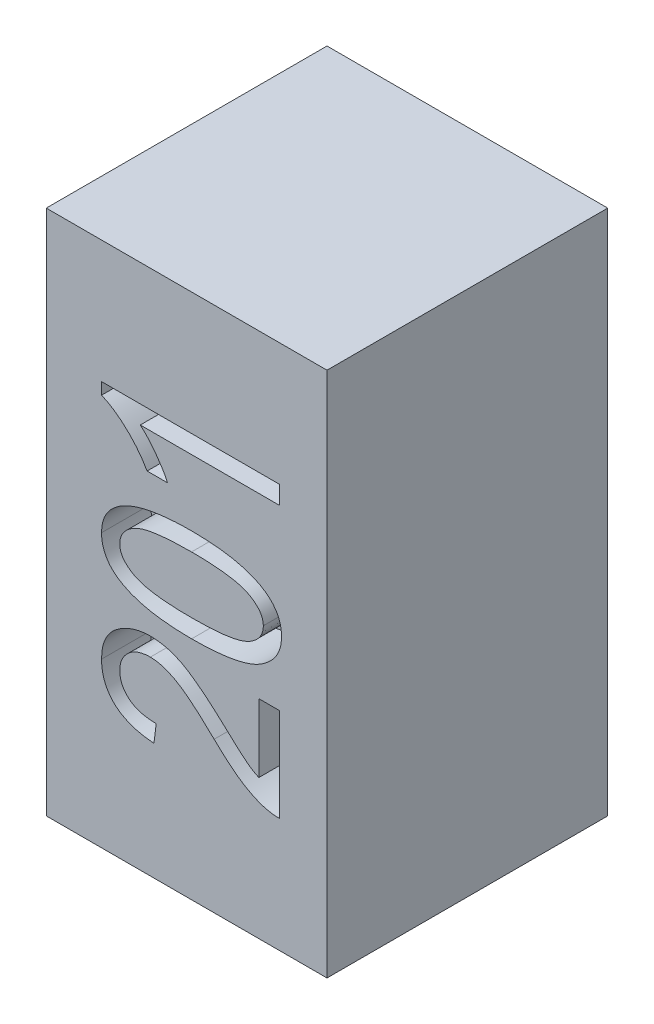
from build123d import *

# Parameters (mm, degrees)
ESQUISSE1_W             = 0.8
ESQUISSE1_H             = 1.5
BOSS_EXTRU_1_DEPTH      = 0.8
ENL_V_MAT_EXTRU_1_DEPTH = 0.14


with BuildPart() as part:
    # Esquisse1 → Boss.-Extru.1 (new body)
    with BuildSketch(Plane.XY):
        Rectangle(ESQUISSE1_W, ESQUISSE1_H)
    extrude(amount=BOSS_EXTRU_1_DEPTH)

    # Esquisse2 → Enlèv. mat.-Extru.1 (cut)
    with BuildSketch(Plane.XY.offset(0.8)):
        with BuildLine():
            Line((0.205570813, -0.157792208), (0.264012371, -0.157792208))
            Line((0.264012371, -0.157792208), (0.264012371, -0.424025974))
            add(Edge.make_bspline(
                [(0.264012371, -0.424025974), (0.260967321, -0.424038301), (0.254798001, -0.424063275), (0.245392327, -0.423232959), (0.235758937, -0.421527003), (0.22576932, -0.41934867), (0.215554854, -0.416260038), (0.205065936, -0.412478951), (0.194328572, -0.408017717), (0.183279597, -0.402793554), (0.171811295, -0.396690753), (0.159978819, -0.389318491), (0.147562351, -0.38089399), (0.134716726, -0.371213142), (0.12131985, -0.360450116), (0.10743377, -0.348551795), (0.092982188, -0.33556787), (0.083383466, -0.326315361), (0.078440131, -0.321550325)],
                knots=[0, 0, 0, 0, 0.672196011, 1.361880106, 2.081368845, 2.831486093, 3.618364569, 4.435734711, 5.292876118, 6.184871288, 7.133796945, 8.159796293, 9.26180684, 10.446293416, 11.710635831, 13.056147575, 14.483918136, 16, 16, 16, 16], degree=3))
            add(Edge.make_bspline(
                [(0.078440131, -0.321550325), (0.072713346, -0.316013609), (0.061686867, -0.305353093), (0.045405594, -0.290349435), (0.030272354, -0.276717105), (0.016013492, -0.264728468), (0.002823211, -0.254170682), (-0.009279632, -0.244937524), (-0.020569702, -0.237470246), (-0.033854091, -0.229407709), (-0.049668946, -0.221721226), (-0.068103661, -0.214925939), (-0.085924545, -0.210535314), (-0.097673474, -0.210000119), (-0.103378051, -0.20974026)],
                knots=[0, 0, 0, 0, 1.312560889, 2.527233899, 3.64818266, 4.668586789, 5.596397896, 6.432357998, 7.175835261, 7.825761013, 8.992224112, 10.065918602, 11.060925749, 12, 12, 12, 12], degree=3))
            add(Edge.make_bspline(
                [(-0.103378051, -0.20974026), (-0.106527438, -0.209776484), (-0.112678521, -0.209847234), (-0.121661412, -0.211049977), (-0.130205936, -0.212764574), (-0.138371976, -0.215030711), (-0.146032105, -0.218235162), (-0.153239808, -0.222118312), (-0.160090015, -0.226558591), (-0.16634486, -0.231739982), (-0.171987603, -0.237403608), (-0.177039168, -0.243386687), (-0.181168118, -0.24979007), (-0.184588242, -0.256481802), (-0.187205121, -0.26350197), (-0.18916589, -0.27083284), (-0.19027981, -0.278496857), (-0.190447822, -0.283701918), (-0.190533084, -0.286343344)],
                knots=[0, 0, 0, 0, 1.164144409, 2.273695819, 3.345940663, 4.387378487, 5.402712487, 6.410231049, 7.41307794, 8.417484468, 9.408318902, 10.367853362, 11.308274301, 12.220303706, 13.142827832, 14.074469365, 15.022846069, 16, 16, 16, 16], degree=3))
            add(Edge.make_bspline(
                [(-0.190533084, -0.286343344), (-0.190473575, -0.289191353), (-0.190357413, -0.294750798), (-0.188904765, -0.302851707), (-0.186978054, -0.3106229), (-0.183932032, -0.317967239), (-0.180250547, -0.325024618), (-0.175445024, -0.331504716), (-0.170081997, -0.337780215), (-0.163790342, -0.343548772), (-0.156646186, -0.34869795), (-0.148843257, -0.35331999), (-0.140187308, -0.357045393), (-0.130892263, -0.360176192), (-0.120846841, -0.362635434), (-0.110082061, -0.364277355), (-0.098602527, -0.36548204), (-0.09069885, -0.365549663), (-0.08663698, -0.365584416)],
                knots=[0, 0, 0, 0, 0.928593091, 1.812656339, 2.680433, 3.537535669, 4.402074609, 5.272376737, 6.164676777, 7.094647554, 8.050991042, 9.035788945, 10.049325173, 11.121325706, 12.235436061, 13.420862991, 14.67452591, 16, 16, 16, 16], degree=3))
            Line((-0.08663698, -0.365584416), (-0.093130486, -0.417532468))
            add(Edge.make_bspline(
                [(-0.093130486, -0.417532468), (-0.099158652, -0.416997129), (-0.110853567, -0.415958547), (-0.127783653, -0.413233388), (-0.143492174, -0.409452488), (-0.158133879, -0.404961846), (-0.171533811, -0.399320802), (-0.183937305, -0.39297169), (-0.195128619, -0.385547018), (-0.205126511, -0.377201807), (-0.213893319, -0.368005987), (-0.221512807, -0.358126763), (-0.228121098, -0.347610622), (-0.233366685, -0.336309555), (-0.237456792, -0.324298316), (-0.240381042, -0.311621674), (-0.242125018, -0.298228873), (-0.242360676, -0.289088026), (-0.242481136, -0.284415584)],
                knots=[0, 0, 0, 0, 1.296016433, 2.514330702, 3.668705393, 4.754684394, 5.790583066, 6.778804856, 7.735156204, 8.660808185, 9.562568342, 10.450784178, 11.329227516, 12.217177451, 13.112894374, 14.042449809, 14.999377131, 16, 16, 16, 16], degree=3))
            add(Edge.make_bspline(
                [(-0.242481136, -0.284415584), (-0.242334143, -0.279370388), (-0.242047925, -0.269546551), (-0.240132911, -0.255252879), (-0.236832082, -0.241881659), (-0.231978869, -0.22952981), (-0.226018589, -0.218063044), (-0.218616149, -0.207585073), (-0.209815824, -0.198106808), (-0.19978414, -0.189679492), (-0.188958514, -0.182229823), (-0.177637379, -0.175730042), (-0.16600985, -0.170091862), (-0.153946139, -0.165685499), (-0.141608258, -0.162005708), (-0.128809151, -0.159693985), (-0.115696505, -0.158066548), (-0.106832896, -0.157884171), (-0.102363441, -0.157792208)],
                knots=[0, 0, 0, 0, 1.141316638, 2.222333051, 3.255980828, 4.24919085, 5.217781249, 6.173073686, 7.14226832, 8.135684626, 9.131102602, 10.111468148, 11.086834621, 12.050425614, 13.014198859, 13.995608887, 14.989290351, 16, 16, 16, 16], degree=3))
            add(Edge.make_bspline(
                [(-0.102363441, -0.157792208), (-0.098336657, -0.157878854), (-0.090335553, -0.158051019), (-0.078397452, -0.159170963), (-0.06661985, -0.161147874), (-0.0548895, -0.163714802), (-0.043388036, -0.167357299), (-0.03193276, -0.171480772), (-0.020653006, -0.176482333), (-0.009328199, -0.182386382), (0.002440813, -0.189300966), (0.014875652, -0.197579536), (0.028301082, -0.207121874), (0.042559397, -0.218122177), (0.057808298, -0.230404693), (0.073926762, -0.244127866), (0.090947705, -0.25924549), (0.102503356, -0.269888004), (0.108472598, -0.275385552)],
                knots=[0, 0, 0, 0, 0.780531358, 1.550893666, 2.321451189, 3.094347453, 3.876089108, 4.657940698, 5.453333384, 6.265487087, 7.132311241, 8.097757185, 9.160053187, 10.324349312, 11.587703087, 12.955031265, 14.427076445, 16, 16, 16, 16], degree=3))
            add(Edge.make_bspline(
                [(0.108472598, -0.275385552), (0.112183556, -0.278879066), (0.119275494, -0.285555453), (0.129562543, -0.294945868), (0.138788252, -0.303550685), (0.147186165, -0.311077417), (0.154576407, -0.317770468), (0.161200839, -0.323272064), (0.166736734, -0.328002498), (0.17560759, -0.334903517), (0.18812033, -0.343612846), (0.199888131, -0.349671617), (0.205570813, -0.352597403)],
                knots=[0, 0, 0, 0, 1.227426371, 2.345710398, 3.354421158, 4.265580894, 5.061720194, 5.755250507, 6.339260457, 6.815034732, 8.461977265, 10, 10, 10, 10], degree=3))
            Line((0.205570813, -0.352597403), (0.205570813, -0.157792208))
        make_face()
        with BuildLine():
            add(Edge.make_bspline(
                [(0.014215293, -0.105844156), (0.00399922, -0.105761675), (-0.015837938, -0.105601516), (-0.044609423, -0.103945955), (-0.071488621, -0.101335365), (-0.096438423, -0.097782979), (-0.119466175, -0.092983086), (-0.140627467, -0.087297112), (-0.15986302, -0.080395334), (-0.177188392, -0.07253586), (-0.192536194, -0.063617321), (-0.205858138, -0.053609545), (-0.217263689, -0.042656053), (-0.22651725, -0.030532414), (-0.233692827, -0.01742418), (-0.238823201, -0.003303949), (-0.241927102, 0.011816903), (-0.242293956, 0.022252539), (-0.242481136, 0.02757711)],
                knots=[0, 0, 0, 0, 1.522177082, 2.955701814, 4.292601031, 5.54555501, 6.7088804, 7.795771162, 8.808034672, 9.750647735, 10.627079958, 11.44753433, 12.228026558, 12.97593222, 13.711165822, 14.446140298, 15.20717461, 16, 16, 16, 16], degree=3))
            add(Edge.make_bspline(
                [(-0.242481136, 0.02757711), (-0.242343665, 0.032325199), (-0.242073528, 0.041655493), (-0.23939859, 0.055203234), (-0.235410952, 0.068049624), (-0.229526205, 0.080007828), (-0.222033299, 0.09121315), (-0.212815704, 0.101532444), (-0.202069659, 0.111232722), (-0.193920757, 0.11675598), (-0.189721395, 0.119602273)],
                knots=[0, 0, 0, 0, 1.02455918, 2.013323352, 2.972239719, 3.92313388, 4.881632631, 5.875512573, 6.905191138, 8, 8, 8, 8], degree=3))
            add(Edge.make_bspline(
                [(-0.189721395, 0.119602273), (-0.184070449, 0.122906761), (-0.172318711, 0.129778793), (-0.15262831, 0.137981703), (-0.130607181, 0.144917692), (-0.106233242, 0.150703779), (-0.079455153, 0.154904795), (-0.050381541, 0.158180211), (-0.0188866, 0.160089392), (0.002916698, 0.160287137), (0.014215293, 0.16038961)],
                knots=[0, 0, 0, 0, 0.745752227, 1.550870435, 2.425309485, 3.376577511, 4.404263406, 5.514061028, 6.71177208, 8, 8, 8, 8], degree=3))
            add(Edge.make_bspline(
                [(0.014215293, 0.16038961), (0.024363793, 0.160307563), (0.044065899, 0.160148278), (0.072667599, 0.158485819), (0.099413205, 0.155885317), (0.124290401, 0.152311336), (0.147263096, 0.147557921), (0.168352217, 0.141789847), (0.187606852, 0.135073629), (0.204927074, 0.127150941), (0.220349309, 0.118262073), (0.233741727, 0.108322617), (0.245102485, 0.097331108), (0.254458804, 0.085318363), (0.261608729, 0.072121412), (0.266860059, 0.058002038), (0.269953242, 0.042794494), (0.270318788, 0.032326147), (0.270505877, 0.026968344)],
                knots=[0, 0, 0, 0, 1.514074965, 2.939396442, 4.273020662, 5.522618968, 6.687464393, 7.770909357, 8.782798299, 9.726643008, 10.608576586, 11.434138097, 12.208514389, 12.960468265, 13.696662544, 14.439073904, 15.201102606, 16, 16, 16, 16], degree=3))
            add(Edge.make_bspline(
                [(0.270505877, 0.026968344), (0.270326276, 0.022188285), (0.269973161, 0.012790151), (0.267293702, -0.001001731), (0.26265949, -0.014045815), (0.256334466, -0.026472562), (0.248066952, -0.038089397), (0.23813936, -0.049170611), (0.226282607, -0.05945192), (0.212666308, -0.069245108), (0.196783903, -0.07804048), (0.178321409, -0.085463968), (0.157341767, -0.09184165), (0.133695973, -0.09686382), (0.107531891, -0.101073339), (0.078722599, -0.103760103), (0.047347402, -0.105514272), (0.025547799, -0.105731322), (0.014215293, -0.105844156)],
                knots=[0, 0, 0, 0, 0.713852874, 1.403515076, 2.08903769, 2.775973907, 3.479633763, 4.213082677, 4.993526966, 5.819329379, 6.714934747, 7.698240864, 8.786642223, 9.986811405, 11.306714678, 12.743554856, 14.307139623, 16, 16, 16, 16], degree=3))
        make_face()
        with BuildLine():
            add(Edge.make_bspline(
                [(0.014012371, -0.053896104), (0.023753266, -0.053804511), (0.042395063, -0.053629225), (0.069098829, -0.052690151), (0.093263495, -0.050876509), (0.114937612, -0.048393253), (0.134119793, -0.045201835), (0.150848178, -0.041355587), (0.165024026, -0.036635794), (0.176895048, -0.031195896), (0.186756649, -0.025071177), (0.19525943, -0.018696281), (0.202450292, -0.01187819), (0.208299131, -0.004596883), (0.212954854, 0.003051859), (0.216227769, 0.011169445), (0.218243365, 0.019699782), (0.218452174, 0.025536849), (0.218557826, 0.02849026)],
                knots=[0, 0, 0, 0, 1.930680258, 3.694870612, 5.294765573, 6.732327541, 8.017244644, 9.14720992, 10.130763445, 10.973463911, 11.728776188, 12.427251247, 13.076760965, 13.687074849, 14.273357039, 14.844695938, 15.415444712, 16, 16, 16, 16], degree=3))
            add(Edge.make_bspline(
                [(0.218557826, 0.02849026), (0.218461448, 0.031277718), (0.218269544, 0.036827992), (0.216075404, 0.044920163), (0.21284843, 0.052714824), (0.208199172, 0.060132169), (0.202087522, 0.067007063), (0.194822671, 0.073654637), (0.186244352, 0.079928672), (0.176250494, 0.085919665), (0.164334792, 0.09141462), (0.150040274, 0.095948655), (0.133344716, 0.09984666), (0.114234082, 0.103069369), (0.092646706, 0.105382264), (0.068626681, 0.107245064), (0.04212419, 0.108170612), (0.023651686, 0.108348653), (0.014012371, 0.108441558)],
                knots=[0, 0, 0, 0, 0.556166894, 1.107416796, 1.665226727, 2.239567038, 2.848554421, 3.499699756, 4.205927923, 4.970429246, 5.826979258, 6.823810641, 7.964115301, 9.254120602, 10.697341843, 12.305131035, 14.071945012, 16, 16, 16, 16], degree=3))
            add(Edge.make_bspline(
                [(0.014012371, 0.108441558), (0.004271518, 0.108349194), (-0.014403992, 0.10817211), (-0.041142077, 0.10724067), (-0.065373037, 0.105413835), (-0.087083205, 0.102947816), (-0.106297316, 0.099745703), (-0.123028138, 0.095903811), (-0.137196882, 0.091173336), (-0.149063029, 0.085777102), (-0.158835349, 0.079572528), (-0.167378709, 0.073287332), (-0.174387666, 0.066283507), (-0.180314862, 0.059035496), (-0.184924591, 0.051282265), (-0.188223602, 0.043041159), (-0.190207639, 0.034367945), (-0.190424146, 0.028432757), (-0.190533084, 0.025446429)],
                knots=[0, 0, 0, 0, 1.925955125, 3.692509702, 5.288489091, 6.729174103, 8.01094651, 9.138146317, 10.1192927, 10.959930748, 11.707705856, 12.404471472, 13.052253553, 13.661073759, 14.251664904, 14.827808546, 15.410204315, 16, 16, 16, 16], degree=3))
            add(Edge.make_bspline(
                [(-0.190533084, 0.025446429), (-0.190439461, 0.022658334), (-0.190254147, 0.017139654), (-0.188047622, 0.009117448), (-0.184829603, 0.001414865), (-0.180135677, -0.005869922), (-0.174171579, -0.012798149), (-0.166923338, -0.019417917), (-0.158283076, -0.025562811), (-0.148336339, -0.031634891), (-0.136325155, -0.036881548), (-0.122113086, -0.041571001), (-0.105368212, -0.045263286), (-0.08624562, -0.048529004), (-0.064620985, -0.050834091), (-0.040602241, -0.052700449), (-0.014099362, -0.053624917), (0.004373086, -0.053803116), (0.014012371, -0.053896104)],
                knots=[0, 0, 0, 0, 0.557032304, 1.102574738, 1.655014845, 2.224515005, 2.830031617, 3.482190151, 4.185515023, 4.951205931, 5.812452911, 6.804401212, 7.944931852, 9.243623836, 10.689090768, 12.299381722, 14.068944907, 16, 16, 16, 16], degree=3))
        make_face(mode=Mode.SUBTRACT)
        with BuildLine():
            Line((0.264012371, 0.400649351), (0.264012371, 0.348701299))
            Line((0.264012371, 0.348701299), (-0.132091525, 0.348701299))
            add(Edge.make_bspline(
                [(-0.132091525, 0.348701299), (-0.128420635, 0.345509744), (-0.120812719, 0.33889525), (-0.109979782, 0.327454218), (-0.098935893, 0.31459158), (-0.088079564, 0.300479474), (-0.077739596, 0.286004739), (-0.068479623, 0.2718196), (-0.060561002, 0.258245001), (-0.056242407, 0.249164099), (-0.054169447, 0.244805195)],
                knots=[0, 0, 0, 0, 0.892632118, 1.84997915, 2.889208393, 4.004565423, 5.117638514, 6.154471911, 7.114131986, 8, 8, 8, 8], degree=3))
            Line((-0.054169447, 0.244805195), (-0.112611006, 0.244805195))
            add(Edge.make_bspline(
                [(-0.112611006, 0.244805195), (-0.116829701, 0.25181069), (-0.125230967, 0.265761693), (-0.139767257, 0.285351389), (-0.15557911, 0.30375761), (-0.172590544, 0.320590852), (-0.190049721, 0.335729369), (-0.20755672, 0.348633198), (-0.224842469, 0.359247236), (-0.236736273, 0.364450865), (-0.242481136, 0.366964286)],
                knots=[0, 0, 0, 0, 1.082336866, 2.155405958, 3.2255179, 4.292702086, 5.32152541, 6.282639852, 7.170492597, 8, 8, 8, 8], degree=3))
            Line((-0.242481136, 0.366964286), (-0.242481136, 0.400649351))
            Line((-0.242481136, 0.400649351), (0.264012371, 0.400649351))
        make_face()
    extrude(amount=-ENL_V_MAT_EXTRU_1_DEPTH, mode=Mode.SUBTRACT)


solid = part.part
